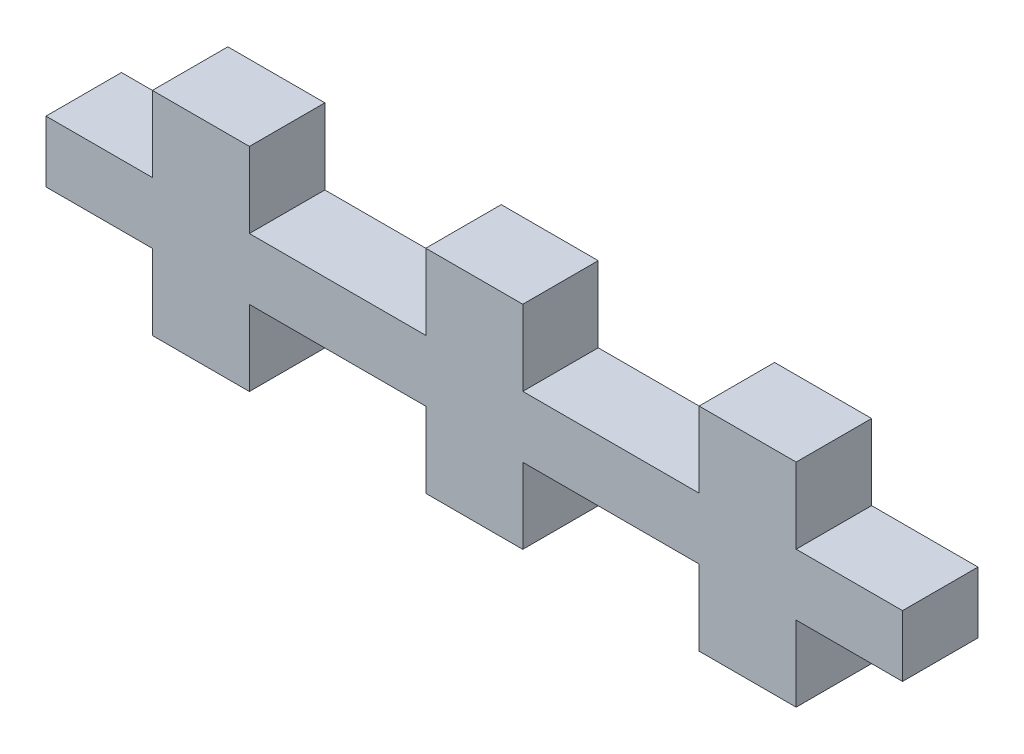
from build123d import *

# Parameters (mm, degrees)
SKETCH1_W           = 4
SKETCH1_H           = 3.175
SKETCH1_W_2         = 42.3
SKETCH1_H_2         = 2.5
BOSS_EXTRUDE1_DEPTH = 3.175
CUT_EXTRUDE2_DEPTH  = 23.175
BOSS_EXTRUDE2_DEPTH = 3.175


with BuildPart() as part:
    # Sketch1 → Boss-Extrude1 (new body)
    with BuildSketch(Plane.XY):
        with Locations((-11.5, -1.5875)):
            Rectangle(SKETCH1_W, SKETCH1_H)
        with Locations((-11.5, 4.0875)):
            Rectangle(SKETCH1_W, SKETCH1_H)
        with Locations((0, 4.0875)):
            Rectangle(SKETCH1_W, SKETCH1_H)
        with Locations((0, -1.5875)):
            Rectangle(SKETCH1_W, SKETCH1_H)
        with Locations((11.5, 4.0875)):
            Rectangle(SKETCH1_W, SKETCH1_H)
        with Locations((11.5, -1.5875)):
            Rectangle(SKETCH1_W, SKETCH1_H)
        with Locations((0, 1.25)):
            Rectangle(SKETCH1_W_2, SKETCH1_H_2)
    extrude(amount=BOSS_EXTRUDE1_DEPTH)

    # Sketch2 → Cut-Extrude2 (cut)
    with BuildSketch(Plane(origin=(0, 2.5, 0), x_dir=(1, 0, 0), z_dir=(0, 1, 0))):
        Polygon((-17.975, 0), (-21.15, 0), (-21.15, -3.175), align=None)
        Polygon((-17.975, -3.175), (-17.975, 0), (-21.15, -3.175), align=None)
        Polygon((21.15, -3.175), (17.975, -3.175), (17.975, 0), align=None)
        Polygon((21.15, -3.175), (17.975, 0), (21.15, 0), align=None)
    extrude(amount=-CUT_EXTRUDE2_DEPTH, mode=Mode.SUBTRACT)

    # Sketch3 → Boss-Extrude2 (add)
    with BuildSketch(Plane.XY.offset(3.175)):
        Polygon((-13.54064, 2.54064), (-18.01564, 2.54064), (-18.01564, -0.04064), (-13.54064, -0.04064), (-13.54064, -3.21564), (-9.45936, -3.21564), (-9.45936, -0.04064), (-2.04064, -0.04064), (-2.04064, -3.21564), (2.04064, -3.21564), (2.04064, -0.04064), (9.45936, -0.04064), (9.45936, -3.21564), (13.54064, -3.21564), (13.54064, -0.04064), (18.01564, -0.04064), (18.01564, 2.54064), (13.54064, 2.54064), (13.54064, 5.71564), (9.45936, 5.71564), (9.45936, 2.54064), (2.04064, 2.54064), (2.04064, 5.71564), (-2.04064, 5.71564), (-2.04064, 2.54064), (-9.45936, 2.54064), (-9.45936, 5.71564), (-13.54064, 5.71564), align=None)
    extrude(amount=-BOSS_EXTRUDE2_DEPTH)


solid = part.part
